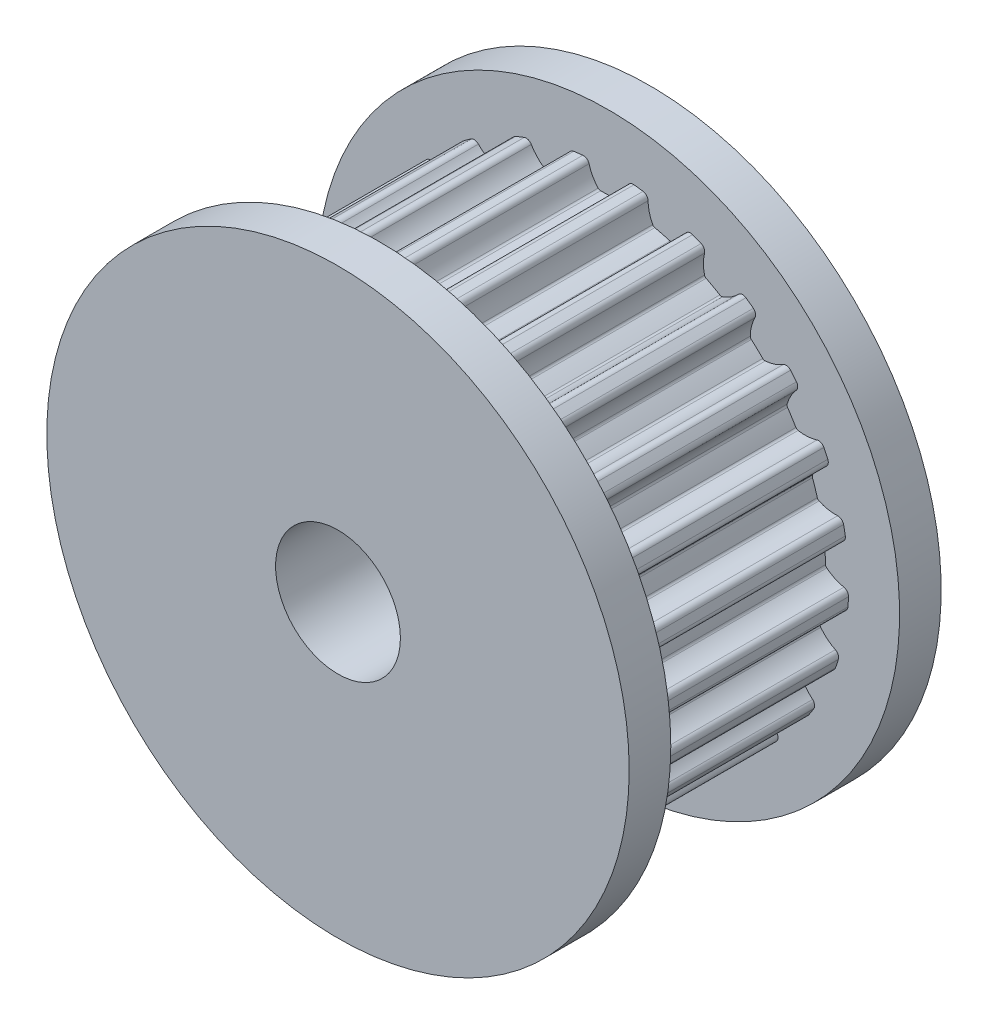
from build123d import *

# Parameters (mm, degrees)
SKETCH_1_R               = 11.555
EXTRUDE_1_DEPTH          = 5.5
CUT_EXTRUDE_1_DEPTH      = 20.698630663
PATTERN_CIRCULAR_1_COUNT = 25
SKETCH_3_R               = 14
EXTRUDE_2_DEPTH          = 2
EXTRUDE_START            = 2
SKETCH_9_R               = 14
EXTRUDE_3_DEPTH          = 2
CUT_EXTRUDE_2_DEPTH      = 8
CUT_EXTRUDE_2_DEPTH_BACK = 25.839484697
SKETCH_4_R               = 3
SKETCH_10_R              = 2
CUT_EXTRUDE_3_DEPTH      = 22.17191536
SKETCH_11_R              = 2
CUT_EXTRUDE_4_DEPTH      = 22.171915395


with BuildPart() as part:
    # 草圖1 → 填料-伸長1 (new, symmetric)
    with BuildSketch(Plane.XY):
        Circle(SKETCH_1_R)
    extrude(amount=EXTRUDE_1_DEPTH, both=True)

    # 草圖2 → 除料-伸長1 (cut, symmetric)
    with BuildSketch(Plane.XY.offset(5.5)):
        with BuildLine():
            ThreePointArc((-0.376101529, 10.438226508), (0, 10.445), (0.376101529, 10.438226508))
            ThreePointArc((0.376101529, 10.438226508), (0.440050692, 10.450027343), (0.492996072, 10.487783692))
            ThreePointArc((0.492996072, 10.487783692), (0.757654953, 10.86109082), (0.929297371, 11.28528584))
            ThreePointArc((0.929297371, 11.28528584), (1.041654025, 11.442459526), (1.229056114, 11.489449337))
            ThreePointArc((1.229056114, 11.489449337), (0, 11.555), (-1.229056114, 11.489449337))
            ThreePointArc((-1.229056114, 11.489449337), (-1.041654025, 11.442459526), (-0.929297371, 11.28528584))
            ThreePointArc((-0.929297371, 11.28528584), (-0.757654953, 10.86109082), (-0.492996072, 10.487783692))
            ThreePointArc((-0.492996072, 10.487783692), (-0.440050692, 10.450027343), (-0.376101529, 10.438226508))
        make_face()
    cut_extrude_1 = extrude(amount=CUT_EXTRUDE_1_DEPTH, both=True, mode=Mode.SUBTRACT)

    # 環狀複製排列1: 除料-伸長1 ×25 about axis
    pattern_circular_1_axis = Axis((0, 0, 5.5), (0, 0, -1))
    for i in range(1, PATTERN_CIRCULAR_1_COUNT):
        add(cut_extrude_1.rotate(pattern_circular_1_axis, i * 360 / PATTERN_CIRCULAR_1_COUNT), mode=Mode.SUBTRACT)

    # 草圖3 → 填料-伸長2 (add)
    with BuildSketch(Plane.XY.offset(5.5)):
        Circle(SKETCH_3_R)
    extrude(amount=EXTRUDE_2_DEPTH)

    # 草圖9 → 填料-伸長3 (add)
    with BuildSketch(Plane(origin=(0, 0, -5.5), x_dir=(-1, 0, 0), z_dir=(0, 0, -1)).offset(EXTRUDE_START)):
        Circle(SKETCH_9_R)
    extrude(amount=-EXTRUDE_3_DEPTH)

    # 草圖4 → 除料-伸長2 (cut, two sides: drawn at the far end of the back side and taken through both)
    with BuildSketch(Plane.XY.offset(7.5).offset(-CUT_EXTRUDE_2_DEPTH_BACK)):
        Circle(SKETCH_4_R)
    extrude(amount=CUT_EXTRUDE_2_DEPTH + CUT_EXTRUDE_2_DEPTH_BACK, mode=Mode.SUBTRACT)

    # 草圖10 → 除料-伸長3 (cut, through all)
    with BuildSketch(Plane(origin=(0, 0, 0), x_dir=(1, 0, 0), z_dir=(0, 1, 0))):
        Circle(SKETCH_10_R)
    extrude(amount=-CUT_EXTRUDE_3_DEPTH, mode=Mode.SUBTRACT)

    # 草圖11 → 除料-伸長4 (cut, through all)
    with BuildSketch(Plane(origin=(0, 0, 0), x_dir=(0, 0, -1), z_dir=(1, 0, 0))):
        Circle(SKETCH_11_R)
    extrude(amount=-CUT_EXTRUDE_4_DEPTH, mode=Mode.SUBTRACT)


solid = part.part
